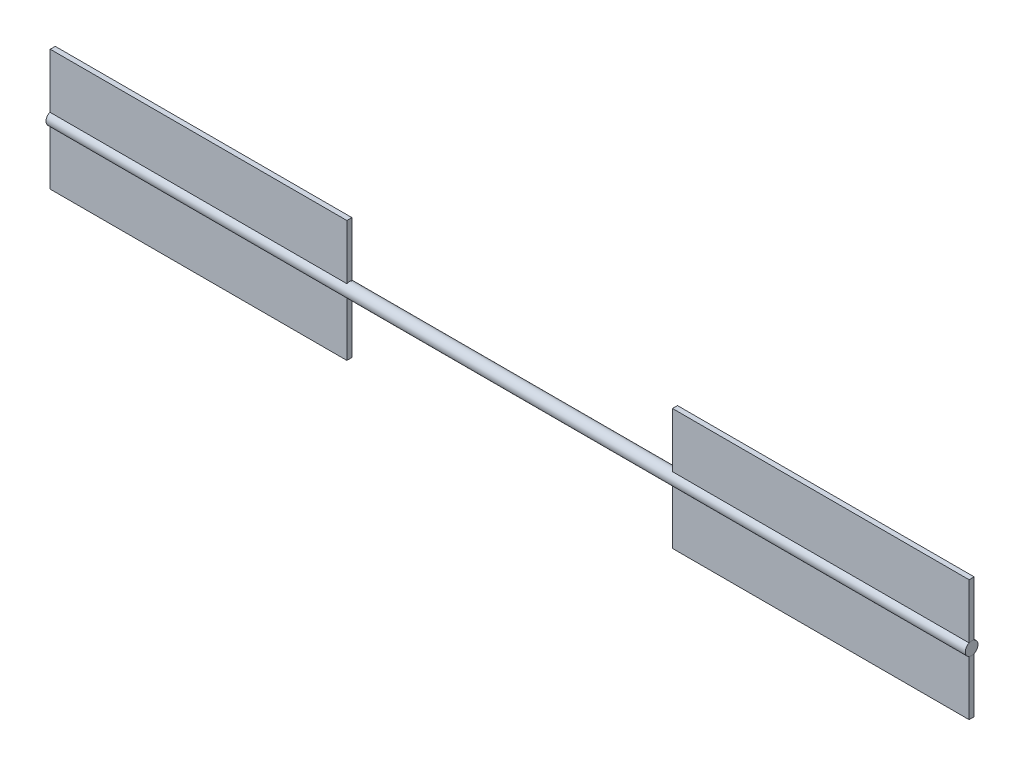
from build123d import *

# Parameters (mm, degrees)
SKETCH6_R                = 25.4
BOSS_EXTRUDE1_DEPTH      = 3660
BOSS_EXTRUDE3_DEPTH      = 10
BOSS_EXTRUDE3_DEPTH_BACK = 10
SKETCH7_W                = 1181.1
SKETCH7_H                = 482.6


with BuildPart() as part:
    # Sketch6 → Boss-Extrude1 (new body)
    with BuildSketch(Plane(origin=(2459.529716421, 0, 0), x_dir=(0, 0, -1), z_dir=(1, 0, 0))):
        with Locations((-197.8, 0)):
            Circle(SKETCH6_R)
    extrude(amount=-BOSS_EXTRUDE1_DEPTH)

    # Sketch7 → Boss-Extrude3 (add, two sides: drawn at the far end of the back side and taken through both)
    with BuildSketch(Plane(origin=(0, 0, 197.8), x_dir=(-1, 0, 0), z_dir=(0, 0, -1)).offset(-BOSS_EXTRUDE3_DEPTH_BACK)):
        with Locations((-1868.912021376, 0)):
            Rectangle(SKETCH7_W, SKETCH7_H)
        with Locations((608.445512971, 0)):
            Rectangle(SKETCH7_W, SKETCH7_H)
    extrude(amount=BOSS_EXTRUDE3_DEPTH + BOSS_EXTRUDE3_DEPTH_BACK)


solid = part.part
